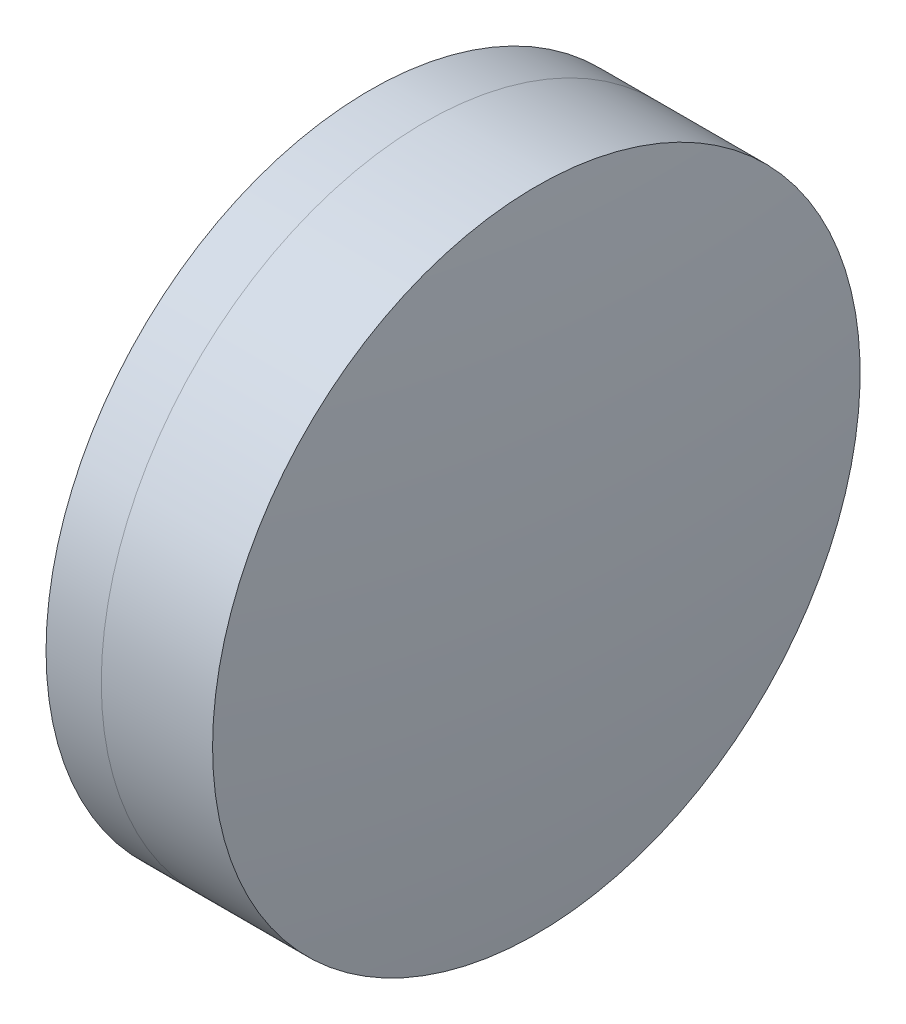
from build123d import *


with BuildPart() as part:
    # 草图1 one side → 旋转1 (revolve)
    with BuildSketch(Plane(origin=(0, 0, 0), x_dir=(1, 0, 0), z_dir=(0, 1, 0)), mode=Mode.PRIVATE) as revolve_1_sk:
        with BuildLine():
            ThreePointArc((26.654863358, 8), (25.891025905, 4.032370041), (25.63504348, 0))
            Line((25.63504348, 0), (29.43504348, 0))
            ThreePointArc((29.43504348, 0), (29.078365228, 4.062157147), (28.019245909, 8))
            Line((28.019245909, 8), (26.654863358, 8))
        make_face()
    revolve(revolve_1_sk.sketch.rotate(Axis((-9.702612178, 0, 0), (1, 0, 0)), 180), axis=Axis((-9.702612178, 0, 0), (1, 0, 0)))  # turned: the seam where the file's is


with BuildPart() as body_2:
    # 草图2 one side → 旋转3 (revolve)
    with BuildSketch(Plane(origin=(0, 0, 0), x_dir=(1, 0, 0), z_dir=(0, 1, 0)), mode=Mode.PRIVATE) as revolve_3_sk:
        with BuildLine():
            Line((30.769536435, 8), (28.019245909, 8))
            ThreePointArc((28.019245909, 8), (29.078365228, 4.062157147), (29.43504348, 0))
            Line((29.43504348, 0), (31.23504348, 0))
            ThreePointArc((31.23504348, 0), (31.118568375, 4.006766053), (30.769536435, 8))
        make_face()
    revolve(revolve_3_sk.sketch.rotate(Axis((-0.551919993, 0, 0), (1, 0, 0)), 180), axis=Axis((-0.551919993, 0, 0), (1, 0, 0)))  # turned: the seam where the file's is


solid = Compound([part.part, body_2.part])
